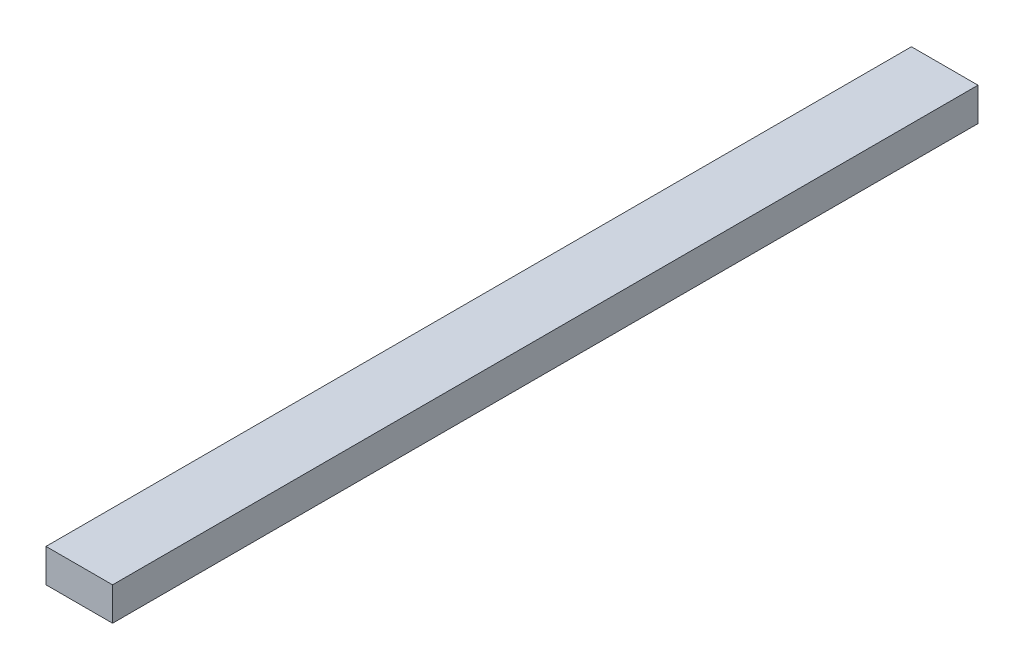
from build123d import *

# Parameters (mm, degrees)
SKETCH2_W           = 50.8
SKETCH2_H           = 25.4
BOSS_EXTRUDE1_DEPTH = 660.4


with BuildPart() as part:
    # Sketch2 → Boss-Extrude1 (new body)
    with BuildSketch(Plane.XY):
        with Locations((25.4, 12.7)):
            Rectangle(SKETCH2_W, SKETCH2_H)
    extrude(amount=BOSS_EXTRUDE1_DEPTH)


solid = part.part
